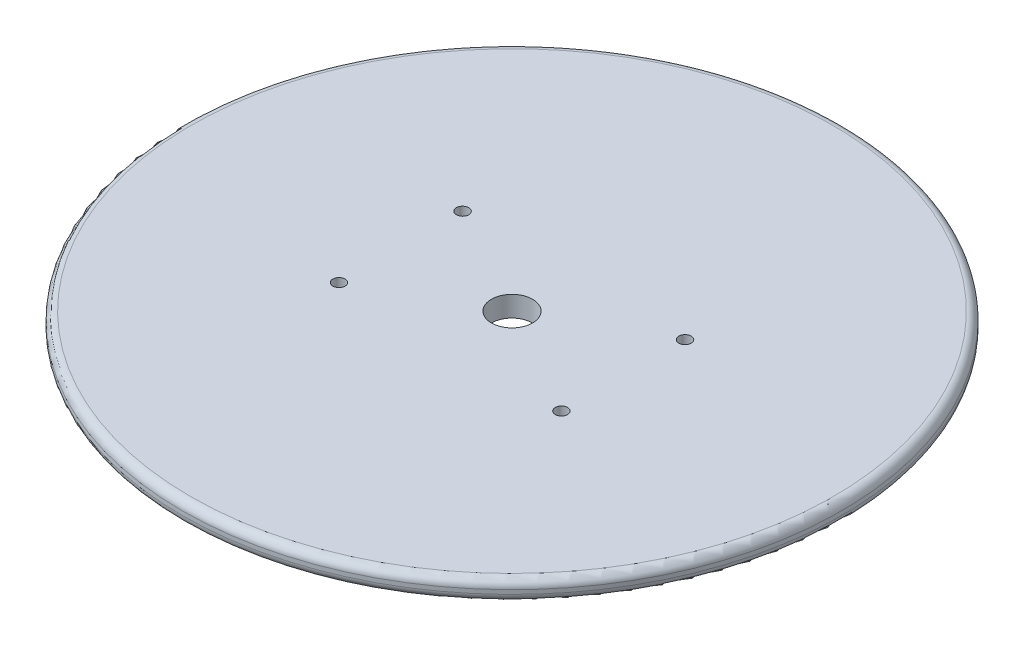
from build123d import *

# Parameters (mm, degrees)
SKETCH1_R           = 80
BOSS_EXTRUDE1_DEPTH = 5
FILLET1_R           = 2
SKETCH2_R           = 5
CUT_EXTRUDE1_DEPTH  = 5
CUT_EXTRUDE2_DEPTH  = 6


with BuildPart() as part:
    # Sketch1 → Boss-Extrude1 (new body)
    with BuildSketch(Plane(origin=(0, 0, 0), x_dir=(1, 0, 0), z_dir=(0, 1, 0))):
        Circle(SKETCH1_R)
    extrude(amount=BOSS_EXTRUDE1_DEPTH)

    # Fillet1
    fillet1_edges = [part.edges().sort_by_distance(p)[0] for p in [
        (-80, 0, 0),
        (-80, 5, 0),
    ]]
    fillet(fillet1_edges, radius=FILLET1_R)

    # Sketch2 → Cut-Extrude1 (cut)
    with BuildSketch(Plane.XZ):
        Circle(SKETCH2_R)
    extrude(amount=-CUT_EXTRUDE1_DEPTH, mode=Mode.SUBTRACT)

    # Sketch3 → Cut-Extrude2 (cut, through all)
    with BuildSketch(Plane(origin=(0, 5, 0), x_dir=(1, 0, 0), z_dir=(0, 1, 0))):
        with BuildLine():
            Line((-27, 13.5), (-27, 15))
            Line((-27, 15), (-25.5, 15))
            ThreePointArc((-25.5, 15), (-28.060660172, 16.060660172), (-27, 13.5))
        make_face()
        with BuildLine():
            Line((-25.5, 15), (-27, 15))
            Line((-27, 15), (-27, 13.5))
            ThreePointArc((-27, 13.5), (-25.939339828, 13.939339828), (-25.5, 15))
        make_face()
        with BuildLine():
            ThreePointArc((-25.5, -15), (-25.939339828, -13.939339828), (-27, -13.5))
            Line((-27, -13.5), (-27, -15))
            Line((-27, -15), (-25.5, -15))
        make_face()
        with BuildLine():
            Line((-27, -15), (-27, -13.5))
            ThreePointArc((-27, -13.5), (-28.060660172, -16.060660172), (-25.5, -15))
            Line((-25.5, -15), (-27, -15))
        make_face()
        with BuildLine():
            ThreePointArc((28.5, -15), (28.060660172, -13.939339828), (27, -13.5))
            Line((27, -13.5), (27, -15))
            Line((27, -15), (25.5, -15))
            ThreePointArc((25.5, -15), (27, -16.5), (28.5, -15))
        make_face()
        with BuildLine():
            Line((27, -15), (27, -13.5))
            ThreePointArc((27, -13.5), (25.939339828, -13.939339828), (25.5, -15))
            Line((25.5, -15), (27, -15))
        make_face()
        with BuildLine():
            ThreePointArc((28.5, 15), (27, 16.5), (25.5, 15))
            Line((25.5, 15), (27, 15))
            Line((27, 15), (27, 13.5))
            ThreePointArc((27, 13.5), (28.060660172, 13.939339828), (28.5, 15))
        make_face()
        with BuildLine():
            Line((27, 15), (25.5, 15))
            ThreePointArc((25.5, 15), (25.939339828, 13.939339828), (27, 13.5))
            Line((27, 13.5), (27, 15))
        make_face()
    extrude(amount=-CUT_EXTRUDE2_DEPTH, mode=Mode.SUBTRACT)


solid = part.part
